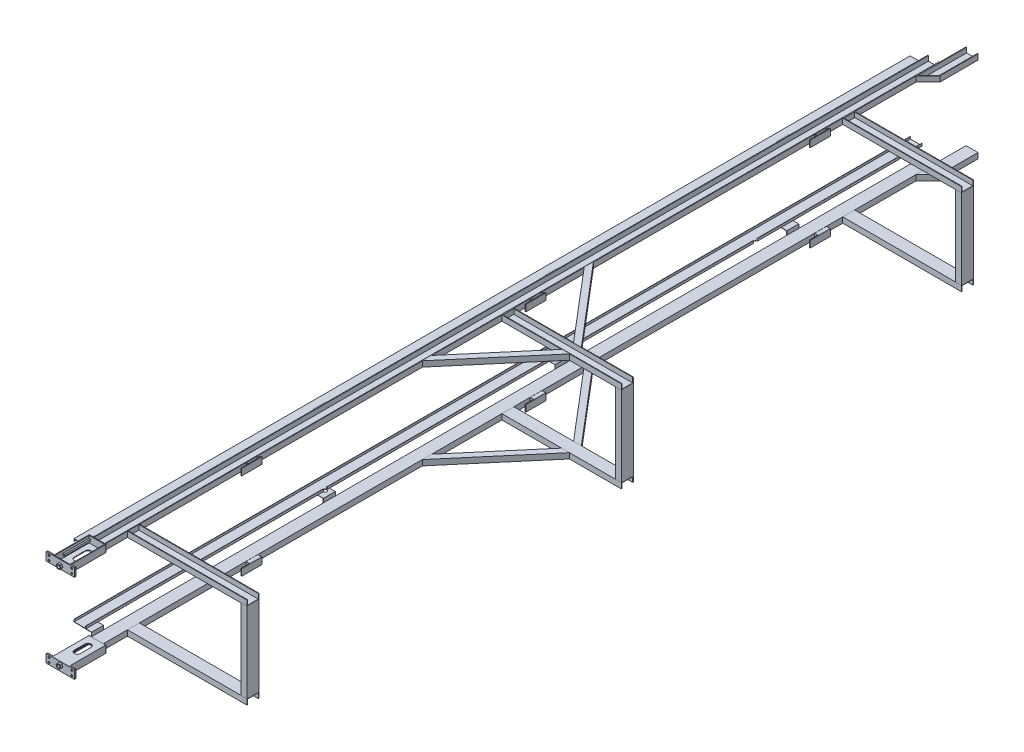
from build123d import *

# Parameters (mm, degrees)
BOSS_EXTRUDE1_DEPTH    = 3500
SKETCH24_W             = 1000
SKETCH24_H             = 100
BOSS_EXTRUDE10_DEPTH   = 46
BOSS_EXTRUDE10_2_DEPTH = 46
SKETCH24_W_2           = 993.755347339
BOSS_EXTRUDE10_3_DEPTH = 46
SHELL1_T               = -5
SHELL2_T               = -5
SKETCH31_W             = 27.98700134
SKETCH31_H             = 100
BOSS_EXTRUDE15_DEPTH   = 45
SHELL4_T               = -5
SKETCH33_W             = 170
SKETCH33_H             = 55
BOSS_EXTRUDE23_DEPTH   = 6
LPATTERN2_COUNT        = 3
LPATTERN2_PITCH        = 2380
SKETCH34_W             = 140
SKETCH34_H             = 60
BOSS_EXTRUDE25_DEPTH   = 6
BOSS_EXTRUDE26_DEPTH   = 300
SKETCH36_W             = 13
SKETCH36_H             = 16
BOSS_EXTRUDE27_DEPTH   = 220
BOSS_EXTRUDE27_2_DEPTH = 220
SKETCH37_W             = 240
SKETCH37_H             = 70
SKETCH37_R             = 8
BOSS_EXTRUDE28_DEPTH   = 6
SKETCH39_R             = 13
CUT_EXTRUDE3_DEPTH     = 6
BOSS_EXTRUDE31_DEPTH   = 46
SHELL6_T               = -5
CUT_EXTRUDE4_DEPTH     = 16
SKETCH57_W             = 6
SKETCH57_H             = 70
BOSS_EXTRUDE44_DEPTH   = 50
SKETCH58_R             = 8
CUT_EXTRUDE6_DEPTH     = 50
SHELL7_T               = -5
SKETCH59_W             = 50
SKETCH59_H             = 70
SKETCH59_R             = 8
BOSS_EXTRUDE45_DEPTH   = 6
FILLET1_R              = 5
FILLET2_R              = 5
FILLET3_R              = 5
BOSS_EXTRUDE46_DEPTH   = 46
BOSS_EXTRUDE46_2_DEPTH = 46
SKETCH61_R             = 13
BOSS_EXTRUDE47_DEPTH   = 15
BOSS_EXTRUDE47_2_DEPTH = 15
SKETCH63_W             = 50
SKETCH63_H             = 100
BOSS_EXTRUDE48_DEPTH   = 670
BOSS_EXTRUDE48_2_DEPTH = 670
BOSS_EXTRUDE48_3_DEPTH = 670
BOSS_EXTRUDE49_DEPTH   = 3500
BOSS_EXTRUDE50_DEPTH   = 100
LPATTERN3_COUNT        = 4
LPATTERN3_PITCH        = 1940
SKETCH66_R             = 15
CUT_EXTRUDE8_DEPTH     = 1459


with BuildPart() as part:
    # Sketch12 → Boss-Extrude1 (new body, symmetric)
    with BuildSketch(Plane.XY):
        Polygon((-50, 0), (50, 0), (50, 46), (45, 46), (45, 5), (-45, 5), (-45, 46), (-50, 46), align=None)
    extrude(amount=BOSS_EXTRUDE1_DEPTH, both=True)


with BuildPart() as body_2:
    # Sketch24 → Boss-Extrude10 (new body)
    with BuildSketch(Plane(origin=(0, 46, 0), x_dir=(1, 0, 0), z_dir=(0, 1, 0))):
        with Locations((550, -3250)):
            Rectangle(SKETCH24_W, SKETCH24_H)
    extrude(amount=-BOSS_EXTRUDE10_DEPTH)

    # Shell1
    shell1_openings = [body_2.faces().sort_by_distance(p)[0] for p in [
        (550, 46, 3250),
        (1050, 23, 3250),
        (50, 23, 3250),
    ]]
    offset(amount=SHELL1_T, openings=shell1_openings, kind=Kind.INTERSECTION)


with BuildPart() as body_3:
    # Sketch24 → Boss-Extrude10 2 (new body)
    with BuildSketch(Plane(origin=(0, 46, 0), x_dir=(1, 0, 0), z_dir=(0, 1, 0))):
        with Locations((550, -115.672019552)):
            Rectangle(SKETCH24_W, SKETCH24_H)
    extrude(amount=-BOSS_EXTRUDE10_2_DEPTH)

    # Shell2
    shell2_openings = [body_3.faces().sort_by_distance(p)[0] for p in [
        (550, 46, 115.672019552),
        (1050, 23, 115.672019552),
    ]]
    offset(amount=SHELL2_T, openings=shell2_openings, kind=Kind.INTERSECTION)


with BuildPart() as body_4:
    # Sketch24 → Boss-Extrude10 3 (new body)
    with BuildSketch(Plane(origin=(0, 46, 0), x_dir=(1, 0, 0), z_dir=(0, 1, 0))):
        with Locations((546.87767367, 2737.522014129)):
            Rectangle(SKETCH24_W_2, SKETCH24_H)
    extrude(amount=-BOSS_EXTRUDE10_3_DEPTH)

    # Shell7
    shell7_openings = [body_4.faces().sort_by_distance(p)[0] for p in [
        (546.87767367, 46, -2737.522014129),
        (1043.755347339, 23, -2737.522014129),
    ]]
    offset(amount=SHELL7_T, openings=shell7_openings, kind=Kind.INTERSECTION)


with BuildPart() as body_5:
    # Sketch31 → Boss-Extrude15 (new body)
    with BuildSketch(Plane(origin=(0, 46, 0), x_dir=(1, 0, 0), z_dir=(0, 1, 0))):
        with Locations((63.99350067, 2501.138441139)):
            Rectangle(SKETCH31_W, SKETCH31_H)
    extrude(amount=-BOSS_EXTRUDE15_DEPTH)

    # Shell4
    shell4_openings = [body_5.faces().sort_by_distance(p)[0] for p in [
        (63.99350067, 46, -2501.138441139),
        (77.98700134, 23.5, -2501.138441139),
        (50, 23.5, -2501.138441139),
    ]]
    offset(amount=SHELL4_T, openings=shell4_openings, kind=Kind.INTERSECTION)


with BuildPart() as body_6:
    # Sketch33 → Boss-Extrude23 (new body)
    with BuildSketch(Plane(origin=(77.98700134, 0, -5338.519788865), x_dir=(0, 0, 1), z_dir=(-1, 0, 0))):
        with Locations((2872.381347726, 28.5)):
            Rectangle(SKETCH33_W, SKETCH33_H)
    extrude(amount=-BOSS_EXTRUDE23_DEPTH)


with BuildPart() as lpattern2_1:
    # LPattern2: pattern copy
    add(body_5.part.moved(Location(Vector(0, 0, 1) * (1 * LPATTERN2_PITCH))))


with BuildPart() as lpattern2_2:
    # LPattern2: pattern copy
    add(body_5.part.moved(Location(Vector(0, 0, 1) * (2 * LPATTERN2_PITCH))))


with BuildPart() as lpattern2_3:
    # LPattern2: pattern copy
    add(body_6.part.moved(Location(Vector(0, 0, 1) * (1 * LPATTERN2_PITCH))))


with BuildPart() as lpattern2_4:
    # LPattern2: pattern copy
    add(body_6.part.moved(Location(Vector(0, 0, 1) * (2 * LPATTERN2_PITCH))))


with BuildPart() as body_11:
    # Sketch34 → Boss-Extrude25 (new body)
    with BuildSketch(Plane.XY.offset(3500)):
        with Locations((0, 30)):
            Rectangle(SKETCH34_W, SKETCH34_H)
    extrude(amount=BOSS_EXTRUDE25_DEPTH)


with BuildPart() as body_12:
    # Sketch35 → Boss-Extrude26 (new body)
    with BuildSketch(Plane.XY.offset(3506)):
        Polygon((70, 0), (70, 60), (65, 60), (65, 5), (-65, 5), (-65, 60), (-70, 60), (-70, 0), align=None)
    extrude(amount=BOSS_EXTRUDE26_DEPTH)

    # Sketch41 → Cut-Extrude4 (cut)
    with BuildSketch(Plane(origin=(0, 5, 0), x_dir=(1, 0, 0), z_dir=(0, 1, 0))):
        with BuildLine():
            Line((25, -3580), (25, -3670))
            ThreePointArc((25, -3670), (0, -3695), (-25, -3670))
            Line((-25, -3670), (-25, -3580))
            ThreePointArc((-25, -3580), (0, -3555), (25, -3580))
        make_face()
    extrude(amount=-CUT_EXTRUDE4_DEPTH, mode=Mode.SUBTRACT)


with BuildPart() as body_13:
    # Sketch36 → Boss-Extrude27 (new body)
    with BuildSketch(Plane.XY.offset(3506)):
        with Locations((-58.5, 31)):
            Rectangle(SKETCH36_W, SKETCH36_H)
    extrude(amount=BOSS_EXTRUDE27_DEPTH)


with BuildPart() as body_14:
    # Sketch36 → Boss-Extrude27 2 (new body)
    with BuildSketch(Plane.XY.offset(3506)):
        with Locations((58.5, 31)):
            Rectangle(SKETCH36_W, SKETCH36_H)
    extrude(amount=BOSS_EXTRUDE27_2_DEPTH)


with BuildPart() as body_15:
    # Sketch37 → Boss-Extrude28 (new body)
    with BuildSketch(Plane.XY.offset(3806)):
        with Locations((0, 35)):
            Rectangle(SKETCH37_W, SKETCH37_H)
        with Locations((-95.100711249, 53.457804047)):
            Circle(SKETCH37_R, mode=Mode.SUBTRACT)
        with Locations((-95.100711249, 16.542195953)):
            Circle(SKETCH37_R, mode=Mode.SUBTRACT)
        with Locations((95.100711249, 16.542195953)):
            Circle(SKETCH37_R, mode=Mode.SUBTRACT)
        with Locations((95.100711249, 53.457804047)):
            Circle(SKETCH37_R, mode=Mode.SUBTRACT)
    extrude(amount=BOSS_EXTRUDE28_DEPTH)

    # Sketch39 → Cut-Extrude3 (cut)
    with BuildSketch(Plane(origin=(0, 0, 3806), x_dir=(-1, 0, 0), z_dir=(0, 0, -1))):
        with Locations((0, 26)):
            Circle(SKETCH39_R)
    extrude(amount=-CUT_EXTRUDE3_DEPTH, mode=Mode.SUBTRACT)

    # Fillet1
    fillet1_edges = [body_15.edges().sort_by_distance(p)[0] for p in [
        (120, 70, 3809),
        (120, 0, 3809),
        (-120, 0, 3809),
        (-120, 70, 3809),
    ]]
    fillet(fillet1_edges, radius=FILLET1_R)


with BuildPart() as body_16:
    # Sketch43 → Boss-Extrude31 (new body)
    with BuildSketch(Plane(origin=(0, 46, 0), x_dir=(1, 0, 0), z_dir=(0, 1, 0))):
        Polygon((50, 3400.031254884), (50, 3720.031254884), (150, 3720.031254884), (150, 3400.031254884), (50, 3300.031254884), align=None)
    extrude(amount=-BOSS_EXTRUDE31_DEPTH)

    # Shell6
    shell6_openings = [body_16.faces().sort_by_distance(p)[0] for p in [
        (100, 23, -3720.031254884),
        (100, 46, -3535.031254884),
    ]]
    offset(amount=SHELL6_T, openings=shell6_openings, kind=Kind.INTERSECTION)


with BuildPart() as body_17:
    # Sketch57 → Boss-Extrude44 (new body)
    with BuildSketch(Plane.ZY.offset(70)):
        with Locations((3803, 35)):
            Rectangle(SKETCH57_W, SKETCH57_H)
    extrude(amount=BOSS_EXTRUDE44_DEPTH)

    # Sketch58 → Cut-Extrude6 (cut)
    with BuildSketch(Plane.XY.offset(3806)):
        with Locations((-95.100711249, 53.457804047)):
            Circle(SKETCH58_R)
        with Locations((-95.100711249, 16.542195953)):
            Circle(SKETCH58_R)
    extrude(amount=-CUT_EXTRUDE6_DEPTH, mode=Mode.SUBTRACT)

    # Fillet3
    fillet3_edges = [body_17.edges().sort_by_distance(p)[0] for p in [
        (-120, 0, 3803),
        (-120, 70, 3803),
    ]]
    fillet(fillet3_edges, radius=FILLET3_R)


with BuildPart() as body_18:
    # Sketch59 → Boss-Extrude45 (new body)
    with BuildSketch(Plane(origin=(0, 0, 3806), x_dir=(-1, 0, 0), z_dir=(0, 0, -1))):
        with Locations((-95, 35)):
            Rectangle(SKETCH59_W, SKETCH59_H)
        with Locations((-95.100711249, 16.542195953)):
            Circle(SKETCH59_R, mode=Mode.SUBTRACT)
        with Locations((-95.100711249, 53.457804047)):
            Circle(SKETCH59_R, mode=Mode.SUBTRACT)
    extrude(amount=BOSS_EXTRUDE45_DEPTH)

    # Fillet2
    fillet2_edges = [body_18.edges().sort_by_distance(p)[0] for p in [
        (120, 70, 3803),
        (120, 0, 3803),
    ]]
    fillet(fillet2_edges, radius=FILLET2_R)


with BuildPart() as body_19:
    # Sketch60 → Boss-Extrude46 (new body)
    with BuildSketch(Plane(origin=(0, 46, 0), x_dir=(1, 0, 0), z_dir=(0, 1, 0))):
        Polygon((50, 523.111164356), (550, -65.672019552), (615.596417333, -65.672019552), (50, 600.355299257), align=None)
    extrude(amount=-BOSS_EXTRUDE46_DEPTH)


with BuildPart() as body_20:
    # Sketch60 → Boss-Extrude46 2 (new body)
    with BuildSketch(Plane(origin=(0, 46, 0), x_dir=(1, 0, 0), z_dir=(0, 1, 0))):
        Polygon((50, -831.69933836), (50, -754.45520346), (550, -165.672019552), (615.596417333, -165.672019552), align=None)
    extrude(amount=-BOSS_EXTRUDE46_2_DEPTH)


with BuildPart() as body_21:
    # Mirror1: mirrored copy
    add(part.part.mirror(Plane(origin=(0, -335, 0), x_dir=(0, 0, 1), z_dir=(0, -1, 0))))


with BuildPart() as body_22:
    # Mirror1 2: mirrored copy
    add(body_2.part.mirror(Plane(origin=(0, -335, 0), x_dir=(0, 0, 1), z_dir=(0, -1, 0))))


with BuildPart() as body_23:
    # Mirror1 3: mirrored copy
    add(body_3.part.mirror(Plane(origin=(0, -335, 0), x_dir=(0, 0, 1), z_dir=(0, -1, 0))))


with BuildPart() as body_24:
    # Mirror1 4: mirrored copy
    add(body_4.part.mirror(Plane(origin=(0, -335, 0), x_dir=(0, 0, 1), z_dir=(0, -1, 0))))


with BuildPart() as body_25:
    # Mirror1 5: mirrored copy
    add(body_5.part.mirror(Plane(origin=(0, -335, 0), x_dir=(0, 0, 1), z_dir=(0, -1, 0))))


with BuildPart() as body_26:
    # Mirror1 6: mirrored copy
    add(body_6.part.mirror(Plane(origin=(0, -335, 0), x_dir=(0, 0, 1), z_dir=(0, -1, 0))))


with BuildPart() as body_27:
    # Mirror1 7: mirrored copy
    add(lpattern2_1.part.mirror(Plane(origin=(0, -335, 0), x_dir=(0, 0, 1), z_dir=(0, -1, 0))))


with BuildPart() as body_28:
    # Mirror1 8: mirrored copy
    add(lpattern2_2.part.mirror(Plane(origin=(0, -335, 0), x_dir=(0, 0, 1), z_dir=(0, -1, 0))))


with BuildPart() as body_29:
    # Mirror1 9: mirrored copy
    add(lpattern2_3.part.mirror(Plane(origin=(0, -335, 0), x_dir=(0, 0, 1), z_dir=(0, -1, 0))))


with BuildPart() as body_30:
    # Mirror1 10: mirrored copy
    add(lpattern2_4.part.mirror(Plane(origin=(0, -335, 0), x_dir=(0, 0, 1), z_dir=(0, -1, 0))))


with BuildPart() as body_31:
    # Mirror1 11: mirrored copy
    add(body_11.part.mirror(Plane(origin=(0, -335, 0), x_dir=(0, 0, 1), z_dir=(0, -1, 0))))


with BuildPart() as body_32:
    # Mirror1 12: mirrored copy
    add(body_12.part.mirror(Plane(origin=(0, -335, 0), x_dir=(0, 0, 1), z_dir=(0, -1, 0))))


with BuildPart() as body_33:
    # Mirror1 13: mirrored copy
    add(body_13.part.mirror(Plane(origin=(0, -335, 0), x_dir=(0, 0, 1), z_dir=(0, -1, 0))))


with BuildPart() as body_34:
    # Mirror1 14: mirrored copy
    add(body_14.part.mirror(Plane(origin=(0, -335, 0), x_dir=(0, 0, 1), z_dir=(0, -1, 0))))


with BuildPart() as body_35:
    # Mirror1 15: mirrored copy
    add(body_15.part.mirror(Plane(origin=(0, -335, 0), x_dir=(0, 0, 1), z_dir=(0, -1, 0))))


with BuildPart() as body_36:
    # Mirror1 16: mirrored copy
    add(body_16.part.mirror(Plane(origin=(0, -335, 0), x_dir=(0, 0, 1), z_dir=(0, -1, 0))))


with BuildPart() as body_37:
    # Mirror1 17: mirrored copy
    add(body_17.part.mirror(Plane(origin=(0, -335, 0), x_dir=(0, 0, 1), z_dir=(0, -1, 0))))


with BuildPart() as body_38:
    # Mirror1 18: mirrored copy
    add(body_18.part.mirror(Plane(origin=(0, -335, 0), x_dir=(0, 0, 1), z_dir=(0, -1, 0))))


with BuildPart() as body_39:
    # Mirror1 19: mirrored copy
    add(body_19.part.mirror(Plane(origin=(0, -335, 0), x_dir=(0, 0, 1), z_dir=(0, -1, 0))))


with BuildPart() as body_40:
    # Mirror1 20: mirrored copy
    add(body_20.part.mirror(Plane(origin=(0, -335, 0), x_dir=(0, 0, 1), z_dir=(0, -1, 0))))


with BuildPart() as body_41:
    # Sketch61 → Boss-Extrude47 (new body)
    with BuildSketch(Plane.XY.offset(3812)):
        Polygon((12.158048727, 43.211604061), (-8.826661993, 45.134981088), (-20.98471072, 27.923377027), (-12.158048727, 8.788395939), (8.826661993, 6.865018912), (20.98471072, 24.076622973), align=None)
        with Locations((0, 26)):
            Circle(SKETCH61_R, mode=Mode.SUBTRACT)
    extrude(amount=BOSS_EXTRUDE47_DEPTH)


with BuildPart() as body_42:
    # Sketch61 → Boss-Extrude47 2 (new body)
    with BuildSketch(Plane.XY.offset(3812)):
        Polygon((-20.528158483, -691.240570151), (-14.385866398, -711.398191815), (6.142292085, -716.157621664), (20.528158483, -700.759429849), (14.385866398, -680.601808185), (-6.142292085, -675.842378336), align=None)
        with Locations((0, -696)):
            Circle(SKETCH61_R, mode=Mode.SUBTRACT)
    extrude(amount=BOSS_EXTRUDE47_2_DEPTH)


with BuildPart() as body_43:
    # Sketch63 → Boss-Extrude48 (new body)
    with BuildSketch(Plane.XZ):
        with Locations((1018.755347339, -2737.522014129)):
            Rectangle(SKETCH63_W, SKETCH63_H)
    extrude(amount=BOSS_EXTRUDE48_DEPTH)


with BuildPart() as body_44:
    # Sketch63 → Boss-Extrude48 2 (new body)
    with BuildSketch(Plane.XZ):
        with Locations((1025, 115.672019552)):
            Rectangle(SKETCH63_W, SKETCH63_H)
    extrude(amount=BOSS_EXTRUDE48_2_DEPTH)


with BuildPart() as body_45:
    # Sketch63 → Boss-Extrude48 3 (new body)
    with BuildSketch(Plane.XZ):
        with Locations((1025, 3250)):
            Rectangle(SKETCH63_W, SKETCH63_H)
    extrude(amount=BOSS_EXTRUDE48_3_DEPTH)


with BuildPart() as body_46:
    # Sketch64 → Boss-Extrude49 (new body, symmetric)
    with BuildSketch(Plane.XY):
        Polygon((-100, -53), (-100, -35), (-196, -35), (-196, -53), (-198, -53), (-198, -33), (-98, -33), (-98, -53), align=None)
    extrude(amount=BOSS_EXTRUDE49_DEPTH, both=True)


with BuildPart() as body_47:
    # Sketch65 → Boss-Extrude50 (new body)
    with BuildSketch(Plane.XY.offset(3500)):
        Polygon((-50, 29.404605041), (-50, 0), (-50, -33), (-135.148139065, -33), (-135.148139065, -31), (-52, -31), (-52, 0), (-52, 29.404605041), align=None)
    extrude(amount=-BOSS_EXTRUDE50_DEPTH)


with BuildPart() as lpattern3_1:
    # LPattern3: pattern copy
    add(body_47.part.moved(Location(Vector(0, 0, -1) * (1 * LPATTERN3_PITCH))))


with BuildPart() as lpattern3_2:
    # LPattern3: pattern copy
    add(body_47.part.moved(Location(Vector(0, 0, -1) * (2 * LPATTERN3_PITCH))))


with BuildPart() as lpattern3_3:
    # LPattern3: pattern copy
    add(body_47.part.moved(Location(Vector(0, 0, -1) * (3 * LPATTERN3_PITCH))))


with BuildPart() as body_51:
    # Mirror2: mirrored copy
    add(lpattern3_3.part.mirror(Plane(origin=(0, -335, 0), x_dir=(0, 0, 1), z_dir=(0, -1, 0))))


with BuildPart() as body_52:
    # Mirror2 2: mirrored copy
    add(body_46.part.mirror(Plane(origin=(0, -335, 0), x_dir=(0, 0, 1), z_dir=(0, -1, 0))))


with BuildPart() as body_53:
    # Mirror2 3: mirrored copy
    add(lpattern3_2.part.mirror(Plane(origin=(0, -335, 0), x_dir=(0, 0, 1), z_dir=(0, -1, 0))))


with BuildPart() as body_54:
    # Mirror2 4: mirrored copy
    add(body_47.part.mirror(Plane(origin=(0, -335, 0), x_dir=(0, 0, 1), z_dir=(0, -1, 0))))


with BuildPart() as body_55:
    # Mirror2 5: mirrored copy
    add(lpattern3_1.part.mirror(Plane(origin=(0, -335, 0), x_dir=(0, 0, 1), z_dir=(0, -1, 0))))


with BuildPart() as cut_extrude8_tool:
    # Sketch66 → Cut-Extrude8 (new body)
    with BuildSketch(Plane(origin=(0, -33, 0), x_dir=(1, 0, 0), z_dir=(0, 1, 0))):
        with Locations((-98, -1496.97)):
            Circle(SKETCH66_R)
        with Locations((-98, 2103.03)):
            Circle(SKETCH66_R)
    extrude(amount=-CUT_EXTRUDE8_DEPTH)


with BuildPart() as body_46_1:
    add(body_46.part)

    # Cut-Extrude8: cut by cut_extrude8_tool
    add(cut_extrude8_tool.part, mode=Mode.SUBTRACT)


with BuildPart() as body_52_1:
    add(body_52.part)

    # Cut-Extrude8: cut by cut_extrude8_tool
    add(cut_extrude8_tool.part, mode=Mode.SUBTRACT)


with BuildPart() as body_55_1:
    add(body_55.part)

    # Cut-Extrude8: cut by cut_extrude8_tool
    add(cut_extrude8_tool.part, mode=Mode.SUBTRACT)


solid = Compound([part.part, body_2.part, body_3.part, body_4.part, body_5.part, body_6.part, lpattern2_1.part, lpattern2_2.part, lpattern2_3.part, lpattern2_4.part, body_11.part, body_12.part, body_13.part, body_14.part, body_15.part, body_16.part, body_17.part, body_18.part, body_19.part, body_20.part, body_21.part, body_22.part, body_23.part, body_24.part, body_25.part, body_26.part, body_27.part, body_28.part, body_29.part, body_30.part, body_31.part, body_32.part, body_33.part, body_34.part, body_35.part, body_36.part, body_37.part, body_38.part, body_39.part, body_40.part, body_41.part, body_42.part, body_43.part, body_44.part, body_45.part, body_47.part, lpattern3_1.part, lpattern3_2.part, lpattern3_3.part, body_51.part, body_53.part, body_54.part, body_46_1.part, body_52_1.part, body_55_1.part])
